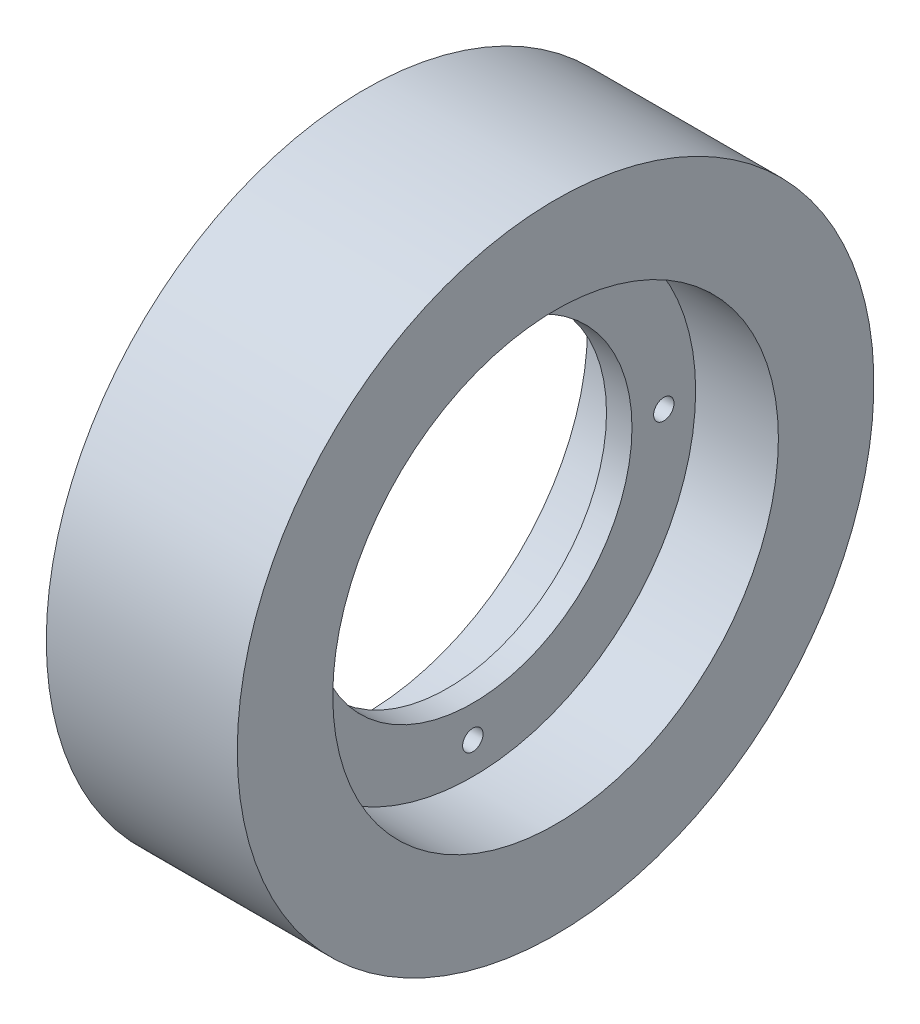
from build123d import *

# Parameters (mm, degrees)
SKETCH3_R          = 1.6
CUT_EXTRUDE1_DEPTH = 18
CIRPATTERN1_COUNT  = 4


with BuildPart() as part:
    # Sketch2 → Revolve1 (revolve)
    with BuildSketch(Plane.XY):
        Polygon((15, 50), (-15, 50), (-15, 35), (-2, 35), (-2, 25), (2, 25), (2, 35), (15, 35), align=None)
    revolve(axis=Axis((0, 0, 0), (1, 0, 0)))

    # Sketch3 → Cut-Extrude1 (cut, through all)
    with BuildSketch(Plane(origin=(2, 0, 0), x_dir=(0, 0, -1), z_dir=(1, 0, 0))):
        with Locations((0, 30)):
            Circle(SKETCH3_R)
    cut_extrude1 = extrude(amount=-CUT_EXTRUDE1_DEPTH, mode=Mode.SUBTRACT)

    # CirPattern1: Cut-Extrude1 ×4 about axis
    cirpattern1_axis = Axis((0, 0, 0), (1, 0, 0))
    for i in range(1, CIRPATTERN1_COUNT):
        add(cut_extrude1.rotate(cirpattern1_axis, i * 360 / CIRPATTERN1_COUNT), mode=Mode.SUBTRACT)


solid = part.part
